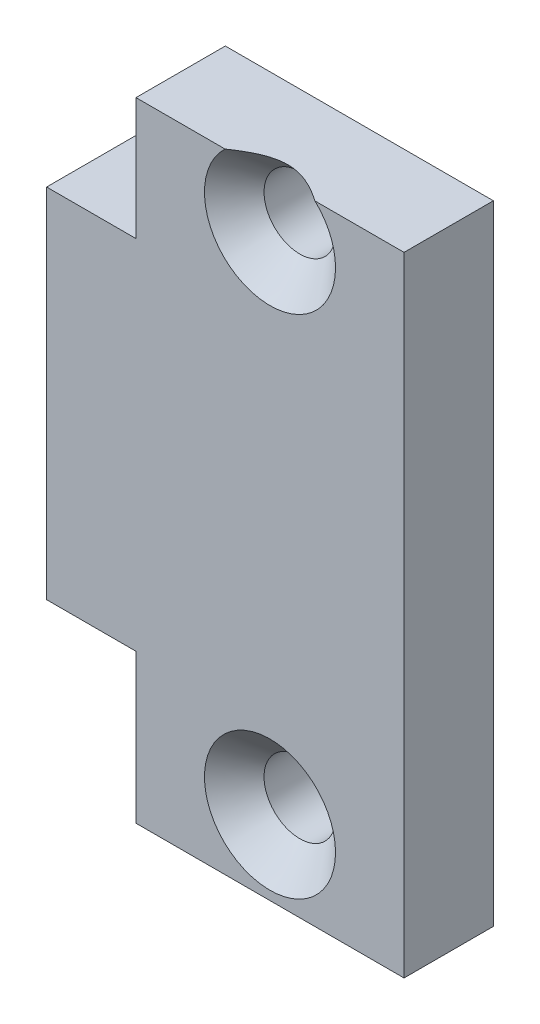
from build123d import *

# Parameters (mm, degrees)
SKETCH1_W                                       = 9
SKETCH1_H                                       = 22
BOSS_EXTRUDE1_DEPTH                             = 3
CSK_FOR_M2_FLAT_HEAD_MACHINE_SCREW1_D           = 2.4
CSK_FOR_M2_FLAT_HEAD_MACHINE_SCREW1_DEPTH       = 10
CSK_FOR_M2_FLAT_HEAD_MACHINE_SCREW1_CSINK_D     = 4.4
CSK_FOR_M2_FLAT_HEAD_MACHINE_SCREW1_CSINK_ANGLE = 90
CSK_FOR_M2_FLAT_HEAD_MACHINE_SCREW1_TIP         = 0.721032743
BOSS_EXTRUDE2_DEPTH                             = 3
SKETCH5_W                                       = 9
SKETCH5_H                                       = 3
CUT_EXTRUDE1_DEPTH                              = 0.9


with BuildPart() as part:
    # Sketch1 → Boss-Extrude1 (new body)
    with BuildSketch(Plane.XY):
        Rectangle(SKETCH1_W, SKETCH1_H)
    extrude(amount=BOSS_EXTRUDE1_DEPTH)

    # CSK for M2 Flat Head Machine Screw1
    with Locations(Plane.XY.offset(3)):
        with Locations((0, 8.5), (0, -8.5)):
            CounterSinkHole(CSK_FOR_M2_FLAT_HEAD_MACHINE_SCREW1_D / 2, CSK_FOR_M2_FLAT_HEAD_MACHINE_SCREW1_CSINK_D / 2, depth=CSK_FOR_M2_FLAT_HEAD_MACHINE_SCREW1_DEPTH, counter_sink_angle=CSK_FOR_M2_FLAT_HEAD_MACHINE_SCREW1_CSINK_ANGLE)
            with Locations((0, 0, -(CSK_FOR_M2_FLAT_HEAD_MACHINE_SCREW1_DEPTH + CSK_FOR_M2_FLAT_HEAD_MACHINE_SCREW1_TIP / 2))):  # 118° drill point
                Cone(0, CSK_FOR_M2_FLAT_HEAD_MACHINE_SCREW1_D / 2, CSK_FOR_M2_FLAT_HEAD_MACHINE_SCREW1_TIP, mode=Mode.SUBTRACT)

    # Sketch4 → Boss-Extrude2 (add)
    with BuildSketch(Plane.ZY.offset(4.5)):
        with BuildLine():
            Line((3, 6), (-2, 6))
            Line((-2, 6), (-2, 5.479963504))
            ThreePointArc((-2, 5.479963504), (-0.910429195, 4.745874502), (0, 3.798683983))
            Line((0, 3.798683983), (0, -3.798683983))
            ThreePointArc((0, -3.798683983), (-0.910429195, -4.745874502), (-2, -5.479963504))
            Line((-2, -5.479963504), (-2, -6))
            Line((-2, -6), (3, -6))
            Line((3, -6), (3, 6))
        make_face()
    extrude(amount=BOSS_EXTRUDE2_DEPTH)

    # Sketch5 → Cut-Extrude1 (cut)
    with BuildSketch(Plane(origin=(0, 11, 0), x_dir=(1, 0, 0), z_dir=(0, 1, 0))):
        with Locations((0, -1.5)):
            Rectangle(SKETCH5_W, SKETCH5_H)
    extrude(amount=-CUT_EXTRUDE1_DEPTH, mode=Mode.SUBTRACT)


solid = part.part
